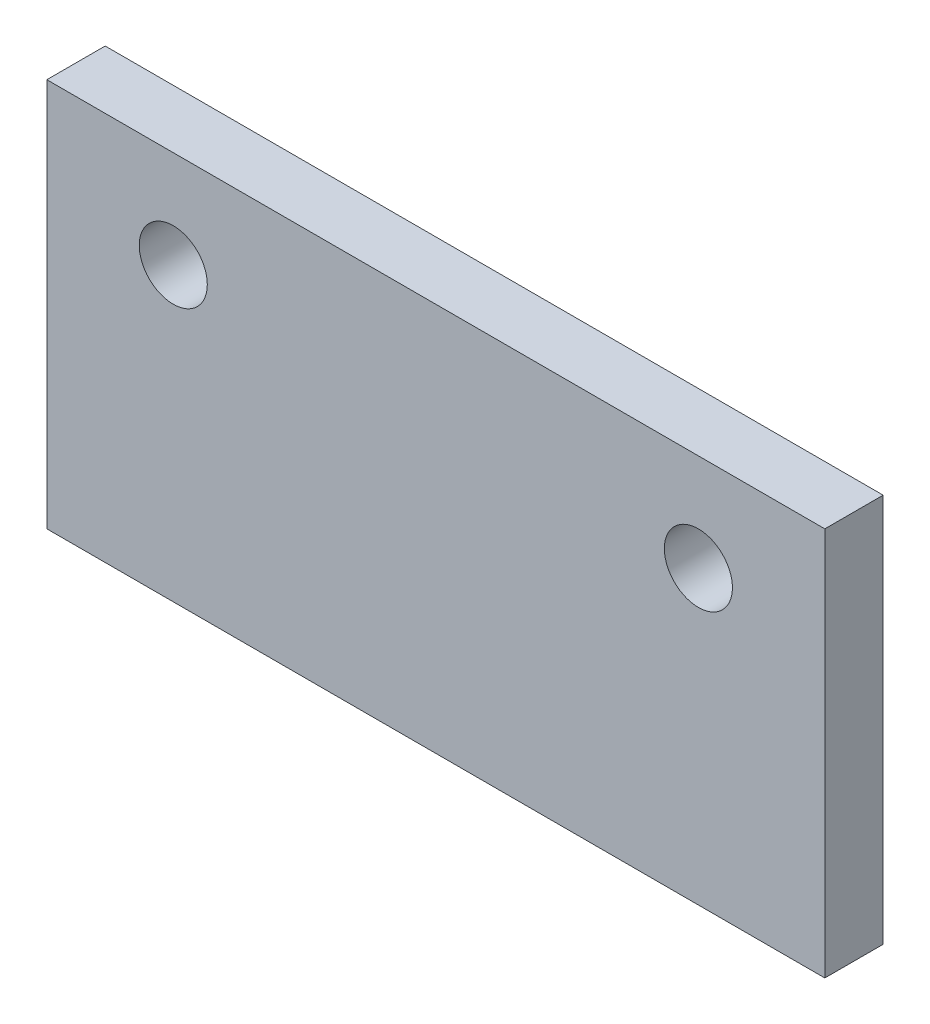
from build123d import *

# Parameters (mm, degrees)
SKETCH_1_W      = 40
SKETCH_1_H      = 20
SKETCH_1_R      = 1.75
EXTRUDE_1_DEPTH = 3


with BuildPart() as part:
    # 草圖1 → 填料-伸長1 (new body)
    with BuildSketch(Plane.XY):
        Rectangle(SKETCH_1_W, SKETCH_1_H)
        with Locations((-13.5, 5)):
            Circle(SKETCH_1_R, mode=Mode.SUBTRACT)
        with Locations((13.5, 5)):
            Circle(SKETCH_1_R, mode=Mode.SUBTRACT)
    extrude(amount=EXTRUDE_1_DEPTH)


solid = part.part
